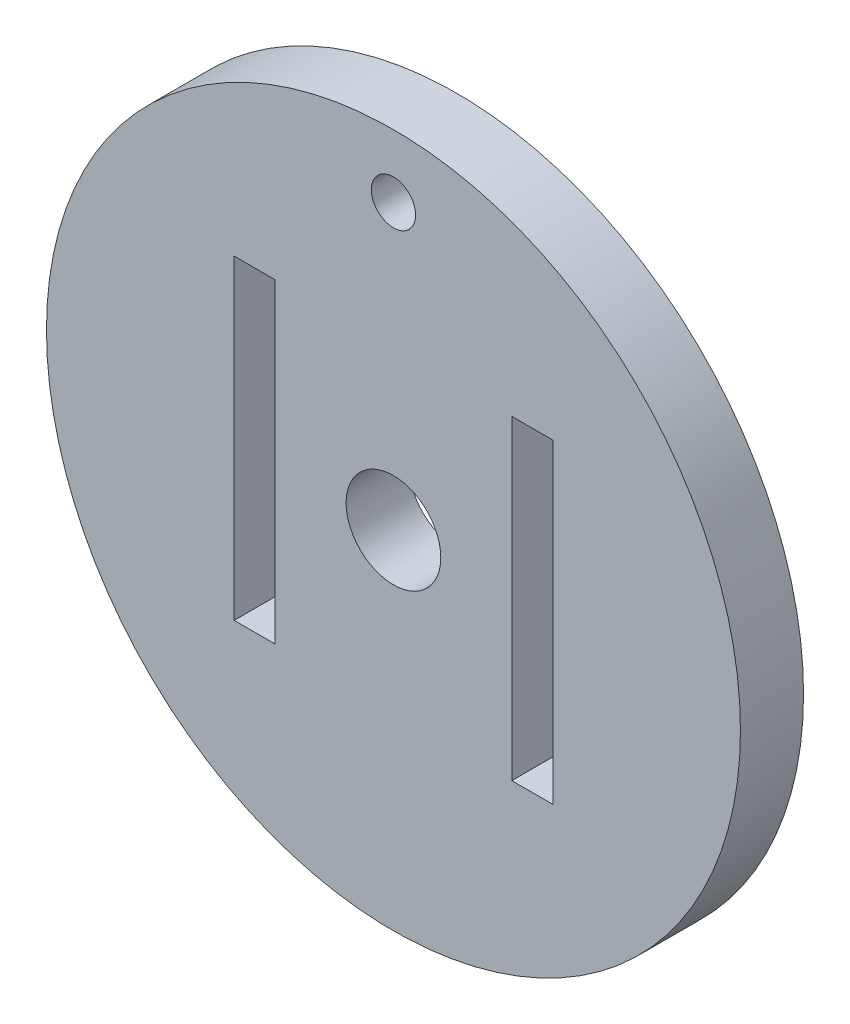
from build123d import *

# Parameters (mm, degrees)
SKETCH1_R           = 11
SKETCH1_R_2         = 1.5
SKETCH1_R_3         = 0.7
SKETCH1_W           = 1.3
SKETCH1_H           = 10
BOSS_EXTRUDE1_DEPTH = 2


with BuildPart() as part:
    # Sketch1 → Boss-Extrude1 (new body)
    with BuildSketch(Plane.XY):
        Circle(SKETCH1_R)
        Circle(SKETCH1_R_2, mode=Mode.SUBTRACT)
        with Locations((0, 9)):
            Circle(SKETCH1_R_3, mode=Mode.SUBTRACT)
        with Locations((-4.4, 0)):
            Rectangle(SKETCH1_W, SKETCH1_H, mode=Mode.SUBTRACT)
        with Locations((4.4, 0)):
            Rectangle(SKETCH1_W, SKETCH1_H, mode=Mode.SUBTRACT)
    extrude(amount=BOSS_EXTRUDE1_DEPTH)


solid = part.part
